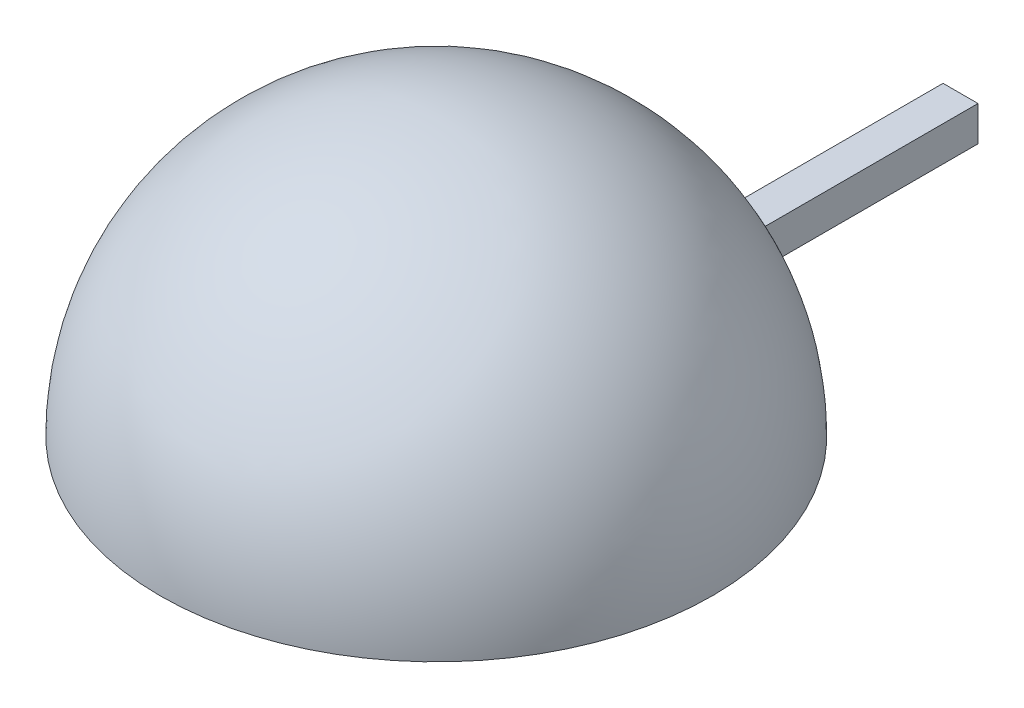
from build123d import *

# Parameters (mm, degrees)
SKETCH_1_W      = 2
SKETCH_1_H      = 15
EXTRUDE_1_DEPTH = 2
REVOLVE_1_ANGLE = 180


with BuildPart() as part:
    # Эскиз1 → Бобышка-Вытянуть1 (new body)
    with BuildSketch(Plane(origin=(0, 0, 0), x_dir=(1, 0, 0), z_dir=(0, 1, 0))):
        with Locations((0, 7.5)):
            Rectangle(SKETCH_1_W, SKETCH_1_H)
    extrude(amount=EXTRUDE_1_DEPTH)

    # Эскиз2 → Повернуть1 (revolve)
    with BuildSketch(Plane(origin=(0, 0, 0), x_dir=(1, 0, 0), z_dir=(0, 1, 0))):
        with BuildLine():
            Line((0, 0.8), (0, 0))
            ThreePointArc((0, 0), (-15, -15), (0, -30))
            Line((0, -30), (0, -30.8))
            ThreePointArc((0, -30.8), (-15.8, -15), (0, 0.8))
        make_face()
    revolve(axis=Axis((0, 0, 15), (0, 0, -1)), revolution_arc=REVOLVE_1_ANGLE)


solid = part.part
